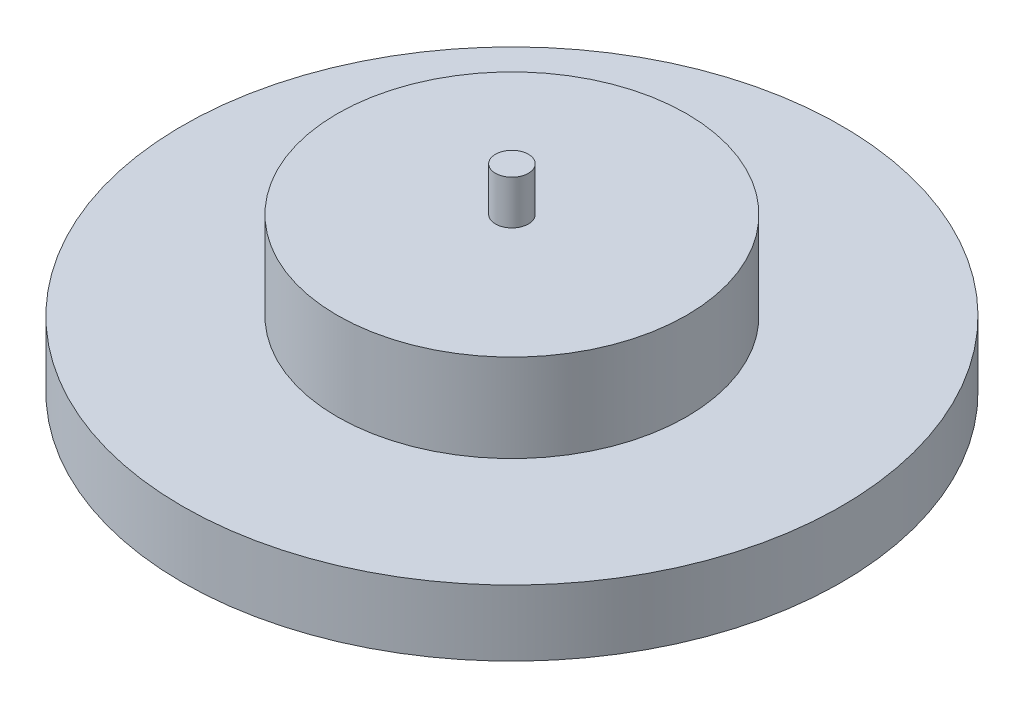
from build123d import *

# Parameters (mm, degrees)
SKETCH_1_R      = 15
EXTRUDE_1_DEPTH = 3
SKETCH_2_R      = 7.95
EXTRUDE_2_DEPTH = 4
SKETCH_3_R      = 0.75
EXTRUDE_3_DEPTH = 2


with BuildPart() as part:
    # 草图1 → 凸台-拉伸1 (new body)
    with BuildSketch(Plane(origin=(0, 0, 0), x_dir=(1, 0, 0), z_dir=(0, 1, 0))):
        Circle(SKETCH_1_R)
    extrude(amount=EXTRUDE_1_DEPTH)

    # 草图2 → 凸台-拉伸2 (add)
    with BuildSketch(Plane(origin=(0, 3, 0), x_dir=(1, 0, 0), z_dir=(0, 1, 0))):
        Circle(SKETCH_2_R)
    extrude(amount=EXTRUDE_2_DEPTH)

    # 草图3 → 凸台-拉伸3 (add)
    with BuildSketch(Plane(origin=(0, 7, 0), x_dir=(1, 0, 0), z_dir=(0, 1, 0))):
        Circle(SKETCH_3_R)
    extrude(amount=EXTRUDE_3_DEPTH)


solid = part.part
